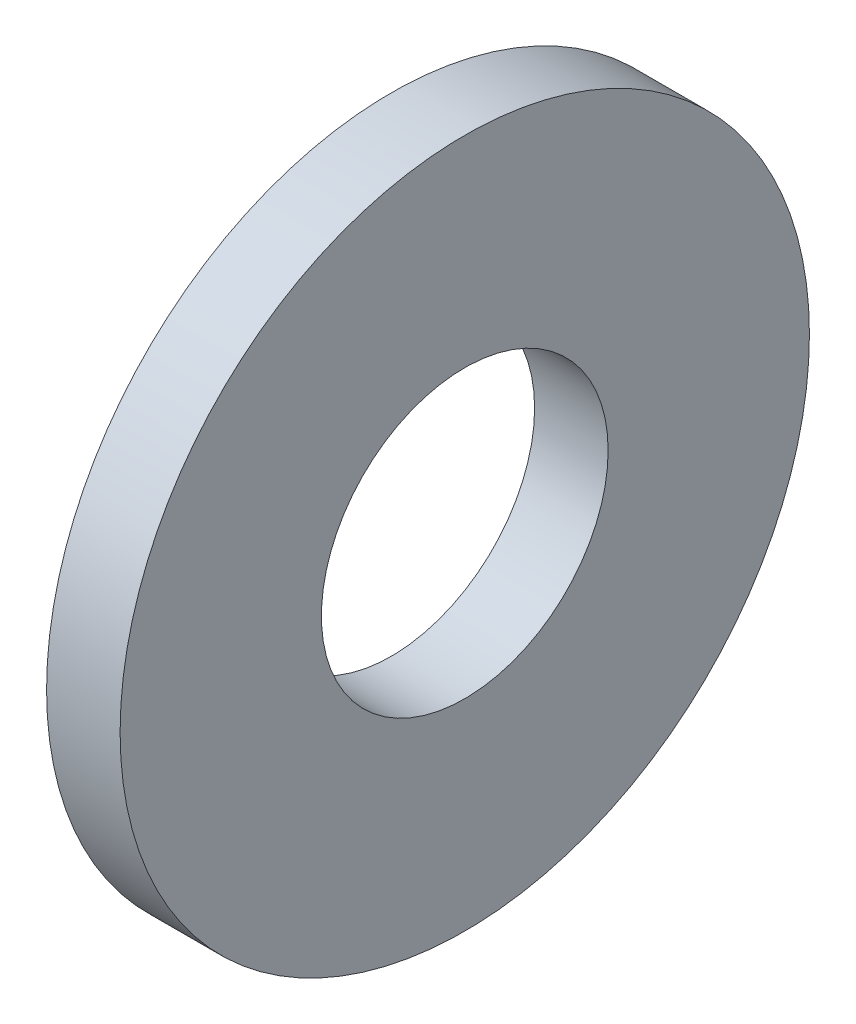
from build123d import *

# Parameters (mm, degrees)
SKETCH1_R           = 9.525
SKETCH1_R_2         = 3.9624
BOSS_EXTRUDE1_DEPTH = 2.032


with BuildPart() as part:
    # Sketch1 → Boss-Extrude1 (new body)
    with BuildSketch(Plane(origin=(0, 0, 0), x_dir=(0, 0, -1), z_dir=(1, 0, 0))):
        Circle(SKETCH1_R)
        Circle(SKETCH1_R_2, mode=Mode.SUBTRACT)
    extrude(amount=BOSS_EXTRUDE1_DEPTH)


solid = part.part
